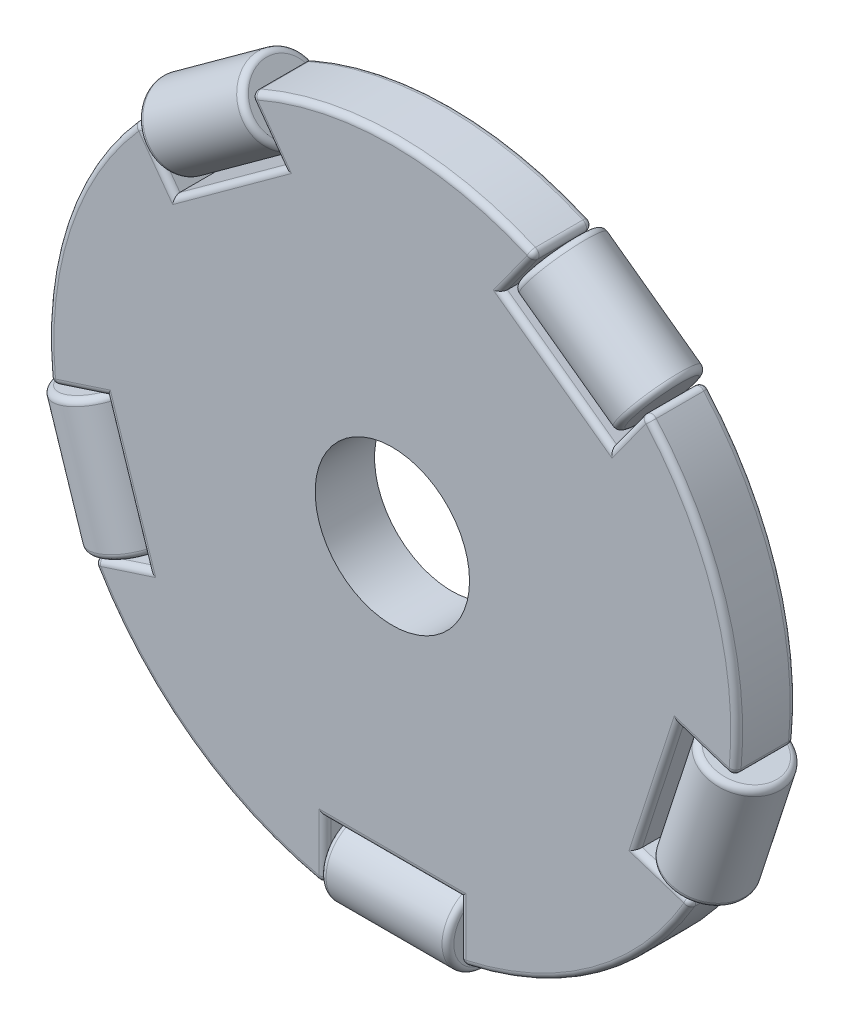
from build123d import *

# Parameters (mm, degrees)
BOSS_EXTRUDE1_DEPTH = 2.5
SKETCH9_W           = 10.763848212
SKETCH9_H           = 3.2
FILLET1_R           = 0.5
FILLET2_R           = 0.5
FILLET3_R           = 0.5
FILLET4_R           = 0.5
FILLET5_R           = 0.5
FILLET6_R           = 0.5
SKETCH12_R          = 6.5
CUT_EXTRUDE1_DEPTH  = 2.5


with BuildPart() as part:
    # Sketch1 → Boss-Extrude1 (new body, symmetric)
    with BuildSketch(Plane.XY):
        with BuildLine():
            Line((-9.193546323, 22.320497613), (-18.387092649, 15.640995224))
            Line((-18.387092649, 15.640995224), (-21.312167739, 19.667015693))
            ThreePointArc((-21.312167739, 19.667015693), (-27.580638973, 8.961492837), (-28.801887669, -3.383972033))
            Line((-28.801887669, -3.383972033), (-24.069016754, -1.846169053))
            Line((-24.069016754, -1.846169053), (-20.557394535, -12.653830947))
            Line((-20.557394535, -12.653830947), (-25.290265449, -14.191633926))
            ThreePointArc((-25.290265449, -14.191633926), (-17.045772316, -23.461492837), (-5.681924106, -28.437927816))
            Line((-5.681924106, -28.437927816), (-5.681924106, -23.461492837))
            Line((-5.681924106, -23.461492837), (5.681924106, -23.461492837))
            Line((5.681924106, -23.461492837), (5.681924106, -28.437927816))
            ThreePointArc((5.681924106, -28.437927816), (17.045772316, -23.461492837), (25.290265449, -14.191633926))
            Line((25.290265449, -14.191633926), (20.557394535, -12.653830947))
            Line((20.557394535, -12.653830947), (24.069016754, -1.846169053))
            Line((24.069016754, -1.846169053), (28.801887669, -3.383972033))
            ThreePointArc((28.801887669, -3.383972033), (27.580638973, 8.961492837), (21.312167739, 19.667015693))
            Line((21.312167739, 19.667015693), (18.387092649, 15.640995224))
            Line((18.387092649, 15.640995224), (9.193546323, 22.320497613))
            Line((9.193546323, 22.320497613), (12.118621413, 26.346518082))
            ThreePointArc((12.118621413, 26.346518082), (0, 29), (-12.118621413, 26.346518082))
            Line((-12.118621413, 26.346518082), (-9.193546323, 22.320497613))
        make_face()
    extrude(amount=BOSS_EXTRUDE1_DEPTH, both=True)

    # Fillet1
    fillet1_edges = [part.edges().sort_by_distance(p)[0] for p in [
        (-26.435452211, -2.615070543, 2.5),
        (-22.313205645, -7.25, 2.5),
        (-22.923829992, -13.422732436, 2.5),
        (-13.790319486, 18.980746418, -2.5),
        (-10.656083868, 24.333507847, -2.5),
        (0, 29, -2.5),
        (10.656083868, 24.333507847, -2.5),
        (13.790319486, 18.980746418, -2.5),
        (-17.045772316, -23.461492837, 2.5),
        (19.849630194, 17.654005459, -2.5),
        (27.580638973, 8.961492837, -2.5),
        (26.435452211, -2.615070543, -2.5),
        (22.313205645, -7.25, -2.5),
        (22.923829992, -13.422732436, -2.5),
        (17.045772316, -23.461492837, -2.5),
        (5.681924106, -25.949710326, -2.5),
        (-5.681924106, -25.949710326, 2.5),
        (0, -23.461492837, -2.5),
        (-5.681924106, -25.949710326, -2.5),
        (-17.045772316, -23.461492837, -2.5),
        (-22.923829992, -13.422732436, -2.5),
        (-22.313205645, -7.25, -2.5),
        (-26.435452211, -2.615070543, -2.5),
        (-27.580638973, 8.961492837, -2.5),
        (-19.849630194, 17.654005459, -2.5),
        (0, -23.461492837, 2.5),
        (5.681924106, -25.949710326, 2.5),
        (17.045772316, -23.461492837, 2.5),
        (-12.118621413, 26.346518082, 0),
        (12.118621413, 26.346518082, 0),
        (21.312167739, 19.667015693, 0),
        (28.801887669, -3.383972033, 0),
        (25.290265449, -14.191633926, 0),
        (5.681924106, -28.437927816, 0),
        (-5.681924106, -28.437927816, 0),
        (-25.290265449, -14.191633926, 0),
        (-28.801887669, -3.383972033, 0),
        (-21.312167739, 19.667015693, 0),
        (22.923829992, -13.422732436, 2.5),
        (22.313205645, -7.25, 2.5),
        (-19.849630194, 17.654005459, 2.5),
        (26.435452211, -2.615070543, 2.5),
        (27.580638973, 8.961492837, 2.5),
        (19.849630194, 17.654005459, 2.5),
        (13.790319486, 18.980746418, 2.5),
        (10.656083868, 24.333507847, 2.5),
        (0, 29, 2.5),
        (-10.656083868, 24.333507847, 2.5),
        (-13.790319486, 18.980746418, 2.5),
        (-27.580638973, 8.961492837, 2.5),
    ]]
    fillet(fillet1_edges, radius=FILLET1_R)

    # Sketch12 → Cut-Extrude1 (cut, symmetric)
    with BuildSketch(Plane.XY):
        Circle(SKETCH12_R)
    extrude(amount=CUT_EXTRUDE1_DEPTH, both=True, mode=Mode.SUBTRACT)


with BuildPart() as body_2:
    # Sketch2 → Revolve1 (revolve)
    with BuildSketch(Plane.XY):
        Polygon((-20.201635934, 18.64889028), (-11.493499805, 24.975721517), (-9.612586997, 22.386867135), (-18.320723127, 16.060035898), align=None)
    revolve(axis=Axis((-20.201635934, 18.64889028, 0), (0.809016994, 0.587785252, 0)))

    # Fillet5
    fillet5_edges = [body_2.edges().sort_by_distance(p)[0] for p in [
        (-13.374412612, 27.564575899, 0),
        (-22.082548741, 21.237744662, 0),
    ]]
    fillet(fillet5_edges, radius=FILLET5_R)


with BuildPart() as body_3:
    # Sketch8 → Revolve2 (revolve)
    with BuildSketch(Plane.XY):
        Polygon((-27.305009463, -3.213045489), (-23.97879744, -13.450073472), (-20.935416588, -12.46121909), (-24.261628611, -2.224191107), align=None)
    revolve(axis=Axis((-27.305009463, -3.213045489, 0), (0.309016994, -0.951056516, 0)))

    # Fillet6
    fillet6_edges = [body_3.edges().sort_by_distance(p)[0] for p in [
        (-30.348390315, -4.201899871, 0),
        (-27.022178292, -14.438927854, 0),
    ]]
    fillet(fillet6_edges, radius=FILLET6_R)


with BuildPart() as body_4:
    # Sketch9 → Revolve3 (revolve)
    with BuildSketch(Plane.XY):
        with Locations((0, -25.361492837)):
            Rectangle(SKETCH9_W, SKETCH9_H)
    revolve(axis=Axis((-5.381924106, -26.961492837, 0), (1, 0, 0)))

    # Fillet2
    fillet2_edges = [body_4.edges().sort_by_distance(p)[0] for p in [
        (-5.381924106, -30.161492837, 0),
        (5.381924106, -30.161492837, 0),
    ]]
    fillet(fillet2_edges, radius=FILLET2_R)


with BuildPart() as body_5:
    # Sketch10 → Revolve4 (revolve)
    with BuildSketch(Plane.XY):
        Polygon((23.97879744, -13.450073472), (27.305009463, -3.213045489), (24.261628611, -2.224191107), (20.935416588, -12.46121909), align=None)
    revolve(axis=Axis((23.97879744, -13.450073472, 0), (0.309016994, 0.951056516, 0)))

    # Fillet3
    fillet3_edges = [body_5.edges().sort_by_distance(p)[0] for p in [
        (27.022178292, -14.438927854, 0),
        (30.348390315, -4.201899871, 0),
    ]]
    fillet(fillet3_edges, radius=FILLET3_R)


with BuildPart() as body_6:
    # Sketch11 → Revolve5 (revolve)
    with BuildSketch(Plane.XY):
        Polygon((20.201635934, 18.64889028), (11.493499805, 24.975721517), (9.612586997, 22.386867135), (18.320723127, 16.060035898), align=None)
    revolve(axis=Axis((20.201635934, 18.64889028, 0), (-0.809016994, 0.587785252, 0)))

    # Fillet4
    fillet4_edges = [body_6.edges().sort_by_distance(p)[0] for p in [
        (13.374412612, 27.564575899, 0),
        (22.082548741, 21.237744662, 0),
    ]]
    fillet(fillet4_edges, radius=FILLET4_R)


solid = Compound([part.part, body_2.part, body_3.part, body_4.part, body_5.part, body_6.part])
